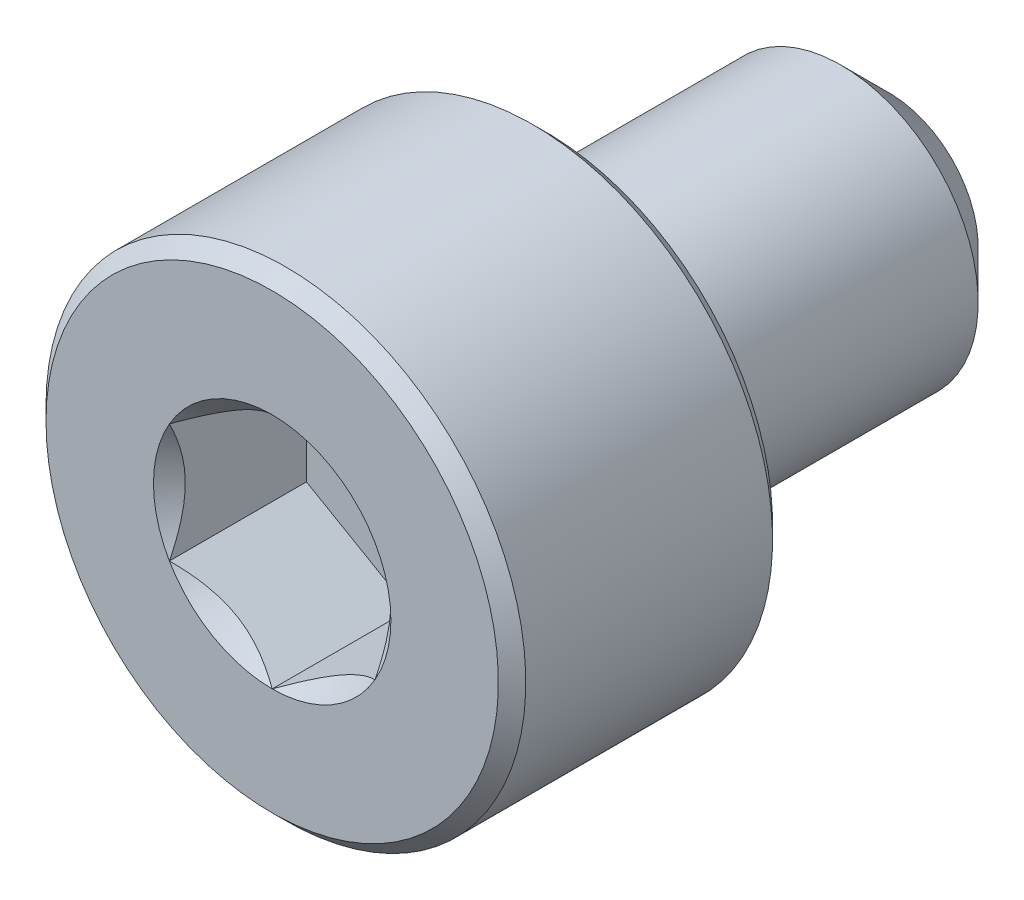
from build123d import *

# Parameters (mm, degrees)
CUT_EXTRUDE1_START = -2
CUT_EXTRUDE1_DEPTH = 2
SKETCH4_R          = 1.732050808
CUT_EXTRUDE2_DEPTH = 0.5
CUT_EXTRUDE2_TAPER = 45


with BuildPart() as part:
    # Sketch2 → Revolve1 (revolve)
    with BuildSketch(Plane(origin=(0, 0, 0), x_dir=(0, 0, -1), z_dir=(1, 0, 0))):
        Polygon((-4.3, 3.5), (-0.7, 3.5), (-0.5, 3.3), (-0.5, 2), (3.8, 2), (4.5, 1.3), (4.5, 0), (-4.5, 0), (-4.5, 3.3), align=None)
    revolve(axis=Axis((0, 0, -4.5), (0, 0, 1)))

    # Sketch3 → Cut-Extrude1 (cut)
    with BuildSketch(Plane.XY.offset(4.5).offset(CUT_EXTRUDE1_START)):
        Polygon((0, 1.732050808), (-1.5, 0.866025404), (-1.5, -0.866025404), (0, -1.732050808), (1.5, -0.866025404), (1.5, 0.866025404), align=None)
    extrude(amount=CUT_EXTRUDE1_DEPTH, mode=Mode.SUBTRACT)

    # Sketch4 → Cut-Extrude2 (cut)
    with BuildSketch(Plane.XY.offset(4.5)):
        Circle(SKETCH4_R)
    extrude(amount=-CUT_EXTRUDE2_DEPTH, taper=CUT_EXTRUDE2_TAPER, mode=Mode.SUBTRACT)


solid = part.part
